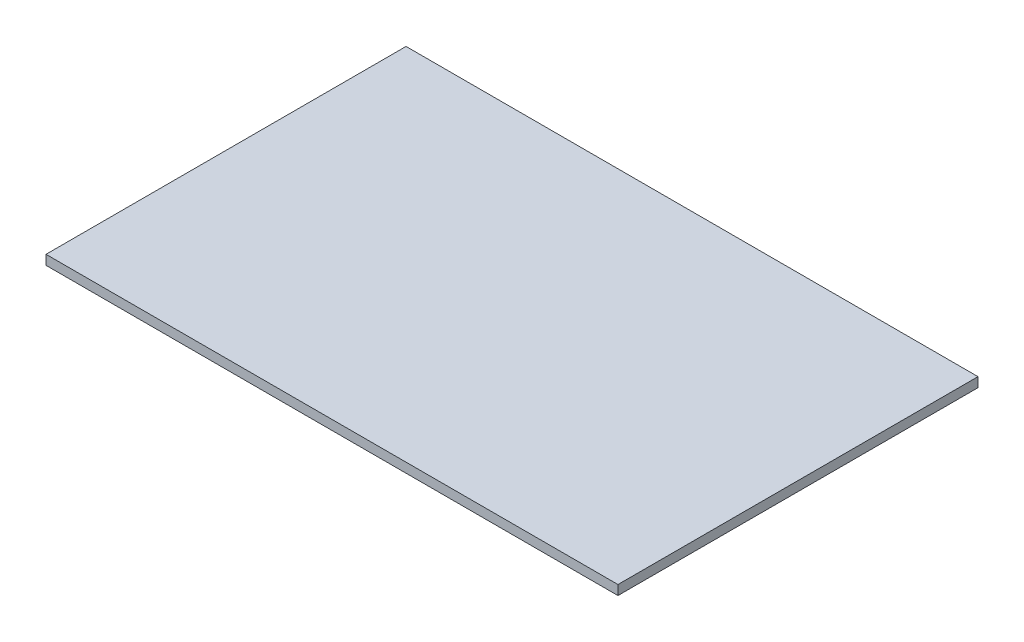
from build123d import *

# Parameters (mm, degrees)
ESBO_O2_W                = 1790
ESBO_O2_H                = 1126.8
RESSALTO_EXTRUS_O1_DEPTH = 30


with BuildPart() as part:
    # Esboço2 → Ressalto-extrusão1 (new body)
    with BuildSketch(Plane(origin=(0, 0, 0), x_dir=(1, 0, 0), z_dir=(0, 1, 0))):
        Rectangle(ESBO_O2_W, ESBO_O2_H)
    extrude(amount=RESSALTO_EXTRUS_O1_DEPTH)


solid = part.part
